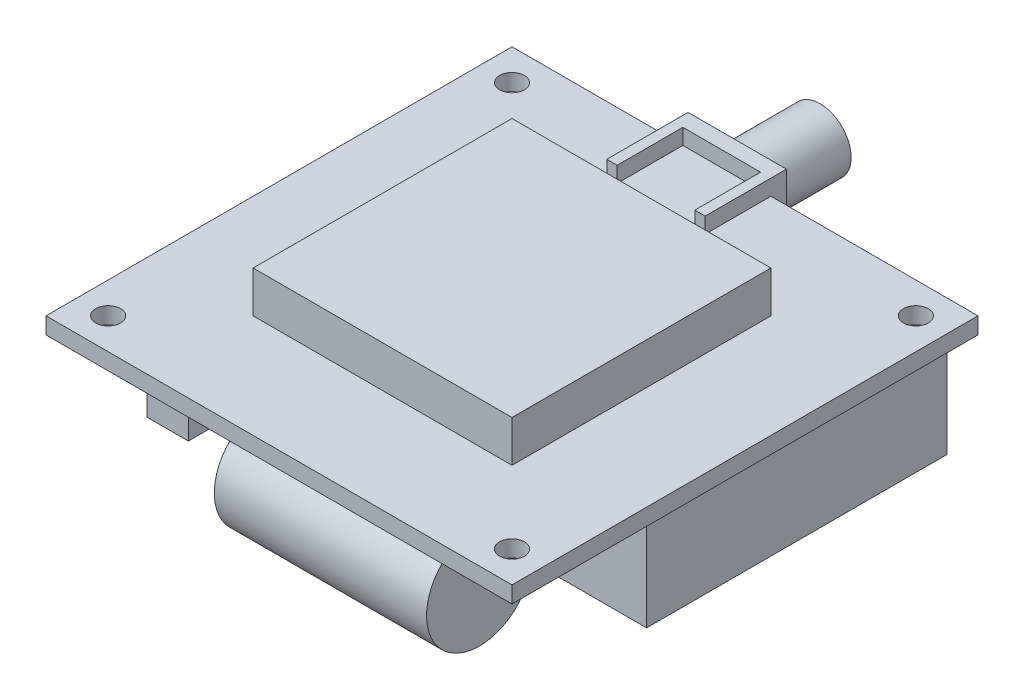
from build123d import *

# Parameters (mm, degrees)
SKETCH1_W                    = 45
SKETCH1_H                    = 45
PCB_DEPTH                    = 1.6
PCB_MOUNTING_HOLES_D         = 2.4
SKETCH4_W                    = 31
SKETCH4_H                    = 29
IRIDIUM_MODEM_DEPTH          = 10
CAPACITOR_START              = -8.25
SKETCH5_R                    = 5.1
CAPACITOR_1_DEPTH            = 20.5
CAPACITOR_START_2            = -1
SKETCH6_R                    = 5.1
CAPACITOR_2_DEPTH            = 20.5
SKETCH7_W                    = 9.5
SKETCH7_H                    = 7.8
BOSS_EXTRUDE5_DEPTH          = 1.5
SKETCH8_R                    = 3
BOSS_EXTRUDE6_DEPTH          = 8
SKETCH9_W                    = 1
SKETCH9_H                    = 1.515102308
BOSS_EXTRUDE7_DEPTH          = 6.35
SKETCH10_W                   = 4
SKETCH10_H                   = 17.8
MOLEX_PICOBLADE_10_POS_DEPTH = 5
SKETCH11_W                   = 25
SKETCH11_H                   = 25
ANTENNA_DEPTH                = 4


with BuildPart() as part:
    # Sketch1 → PCB (new body)
    with BuildSketch(Plane(origin=(0, 0, 0), x_dir=(1, 0, 0), z_dir=(0, 1, 0))):
        Rectangle(SKETCH1_W, SKETCH1_H)
    extrude(amount=PCB_DEPTH)

    # PCB mounting holes (through all)
    with Locations(Plane(origin=(0, 0, 0), x_dir=(-1, 0, 0), z_dir=(0, -1, 0))):
        with Locations((-19.5, -19.5), (19.5, 19.5), (19.5, -19.5), (-19.5, 19.5)):
            Hole(PCB_MOUNTING_HOLES_D / 2)

    # Sketch4 → Iridium Modem (add)
    with BuildSketch(Plane.XZ):
        with Locations((5.5, -6.5)):
            Rectangle(SKETCH4_W, SKETCH4_H)
    extrude(amount=IRIDIUM_MODEM_DEPTH)

    # Sketch7 → Boss-Extrude5 (add)
    with BuildSketch(Plane(origin=(0, 0, -22.5), x_dir=(-1, 0, 0), z_dir=(0, 0, -1))):
        with Locations((2.25, -0.784897692)):
            Rectangle(SKETCH7_W, SKETCH7_H)
    extrude(amount=BOSS_EXTRUDE5_DEPTH)

    # Sketch8 → Boss-Extrude6 (add)
    with BuildSketch(Plane(origin=(0, 0, -24), x_dir=(-1, 0, 0), z_dir=(0, 0, -1))):
        with Locations((2.25, -0.784897692)):
            Circle(SKETCH8_R)
    extrude(amount=BOSS_EXTRUDE6_DEPTH)

    # Sketch9 → Boss-Extrude7 (add)
    with BuildSketch(Plane.XY.offset(-22.5)):
        with Locations((-6.5, 2.357551154)):
            Rectangle(SKETCH9_W, SKETCH9_H)
        with Locations((2, 2.357551154)):
            Rectangle(SKETCH9_W, SKETCH9_H)
    extrude(amount=BOSS_EXTRUDE7_DEPTH)

    # Sketch10 → Molex picoblade 10 pos (add)
    with BuildSketch(Plane.XZ):
        with Locations((-13.75, 10.6)):
            Rectangle(SKETCH10_W, SKETCH10_H)
    extrude(amount=MOLEX_PICOBLADE_10_POS_DEPTH)

    # Sketch11 → Antenna (add)
    with BuildSketch(Plane(origin=(0, 1.6, 0), x_dir=(1, 0, 0), z_dir=(0, 1, 0))):
        Rectangle(SKETCH11_W, SKETCH11_H)
    extrude(amount=ANTENNA_DEPTH)


with BuildPart() as body_2:
    # Sketch5 → Capacitor 1 (new body)
    with BuildSketch(Plane(origin=(22.5, 0, 0), x_dir=(0, 0, -1), z_dir=(1, 0, 0)).offset(CAPACITOR_START)):
        with Locations((-17.4, -5.1)):
            Circle(SKETCH5_R)
    extrude(amount=-CAPACITOR_1_DEPTH)


with BuildPart() as body_3:
    # Sketch6 → Capacitor 2 (new body)
    with BuildSketch(Plane(origin=(0, 0, -22.5), x_dir=(-1, 0, 0), z_dir=(0, 0, -1)).offset(CAPACITOR_START_2)):
        with Locations((17.4, -5.1)):
            Circle(SKETCH6_R)
    extrude(amount=-CAPACITOR_2_DEPTH)


solid = Compound([part.part, body_2.part, body_3.part])
